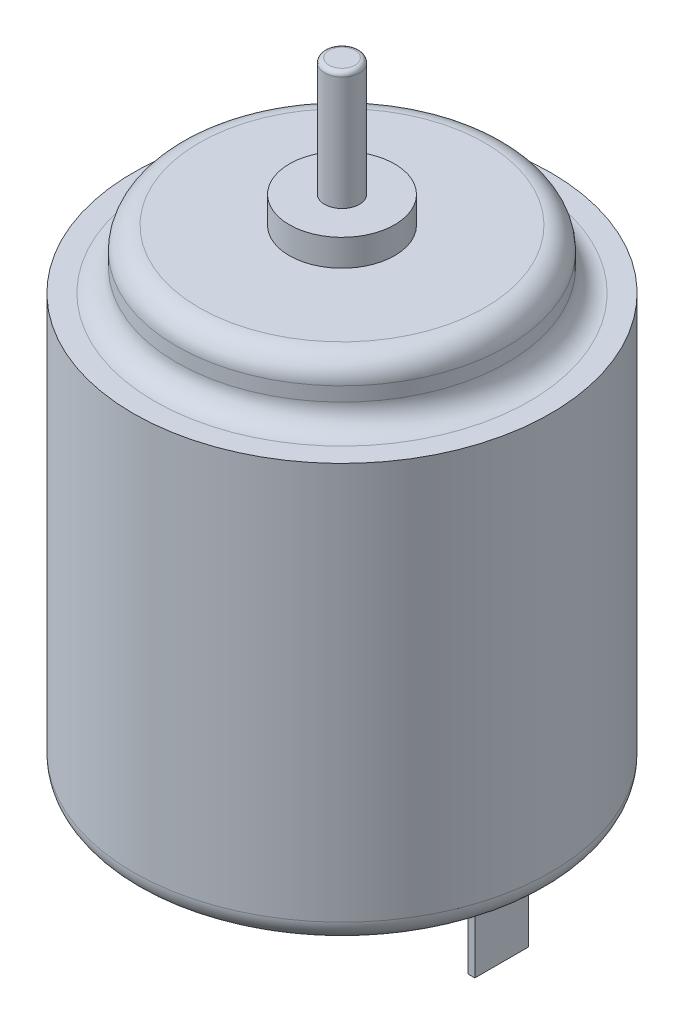
from build123d import *

# Parameters (mm, degrees)
SKETCH1_R           = 11.8745
BOSS_EXTRUDE1_DEPTH = 23.876
SKETCH2_R           = 9.398
BOSS_EXTRUDE2_DEPTH = 3.3401
SKETCH3_R           = 2.9972
BOSS_EXTRUDE3_DEPTH = 1.524
SKETCH4_R           = 0.9906
BOSS_EXTRUDE4_DEPTH = 6.731
SKETCH5_R           = 4.2926
BOSS_EXTRUDE5_DEPTH = 2.032
CUT_EXTRUDE1_DEPTH  = 2.032
SKETCH7_W           = 0.381
SKETCH7_H           = 3.048
BOSS_EXTRUDE6_DEPTH = 4.572
FILLET1_R           = 1.27
FILLET2_R           = 0.254


with BuildPart() as part:
    # Sketch1 → Boss-Extrude1 (new body)
    with BuildSketch(Plane(origin=(0, 0, 0), x_dir=(1, 0, 0), z_dir=(0, 1, 0))):
        Circle(SKETCH1_R)
    extrude(amount=BOSS_EXTRUDE1_DEPTH)

    # Sketch2 → Boss-Extrude2 (add)
    with BuildSketch(Plane(origin=(0, 23.876, 0), x_dir=(1, 0, 0), z_dir=(0, 1, 0))):
        Circle(SKETCH2_R)
    extrude(amount=BOSS_EXTRUDE2_DEPTH)

    # Sketch3 → Boss-Extrude3 (add)
    with BuildSketch(Plane(origin=(0, 27.2161, 0), x_dir=(1, 0, 0), z_dir=(0, 1, 0))):
        Circle(SKETCH3_R)
    extrude(amount=BOSS_EXTRUDE3_DEPTH)

    # Sketch4 → Boss-Extrude4 (add)
    with BuildSketch(Plane(origin=(0, 28.7401, 0), x_dir=(1, 0, 0), z_dir=(0, 1, 0))):
        Circle(SKETCH4_R)
    extrude(amount=BOSS_EXTRUDE4_DEPTH)

    # Sketch5 → Boss-Extrude5 (add)
    with BuildSketch(Plane.XZ):
        Circle(SKETCH5_R)
    extrude(amount=BOSS_EXTRUDE5_DEPTH)

    # Sketch6 → Cut-Extrude1 (cut)
    with BuildSketch(Plane.XZ.offset(2.032)):
        with BuildLine():
            Line((2.16198617, 3.7084), (-2.16198617, 3.7084))
            ThreePointArc((-2.16198617, 3.7084), (0, 4.2926), (2.16198617, 3.7084))
        make_face()
    extrude(amount=-CUT_EXTRUDE1_DEPTH, mode=Mode.SUBTRACT)

    # Sketch7 → Boss-Extrude6 (add)
    with BuildSketch(Plane.XZ):
        with Locations((-8.89, 0)):
            Rectangle(SKETCH7_W, SKETCH7_H)
        with Locations((8.89, 0)):
            Rectangle(SKETCH7_W, SKETCH7_H)
    extrude(amount=BOSS_EXTRUDE6_DEPTH)

    # Fillet1
    fillet1_edges = [part.edges().sort_by_distance(p)[0] for p in [
        (-11.8745, 0, 0),
        (-9.398, 23.876, 0),
        (-9.398, 27.2161, 0),
    ]]
    fillet(fillet1_edges, radius=FILLET1_R)

    # Fillet2
    fillet2_edges = [part.edges().sort_by_distance(p)[0] for p in [
        (-0.9906, 35.4711, 0),
    ]]
    fillet(fillet2_edges, radius=FILLET2_R)


solid = part.part
